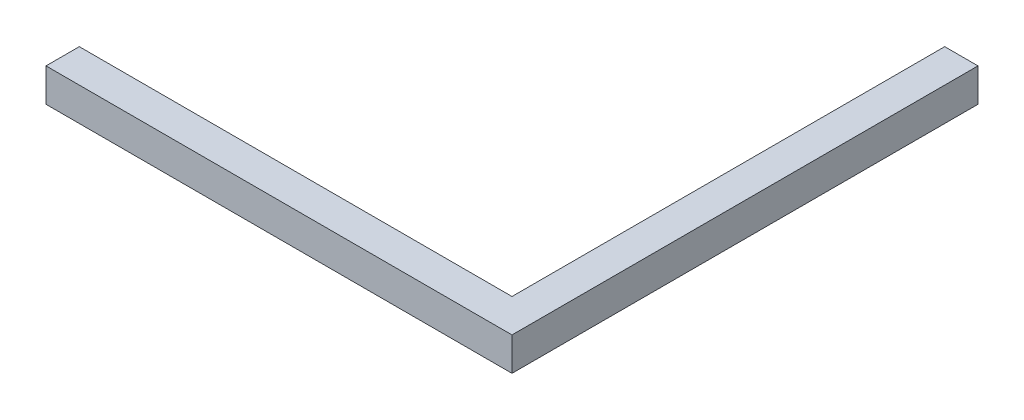
from build123d import *

# Parameters (mm, degrees)
BOSS_EXTRUDE1_DEPTH = 10


with BuildPart() as part:
    # Sketch1 → Boss-Extrude1 (new body)
    with BuildSketch(Plane(origin=(0, 0, 0), x_dir=(1, 0, 0), z_dir=(0, 1, 0))):
        Polygon((-70, -70), (70, -70), (70, 70), (60, 70), (60, -60), (-70, -60), align=None)
    extrude(amount=BOSS_EXTRUDE1_DEPTH)


solid = part.part
